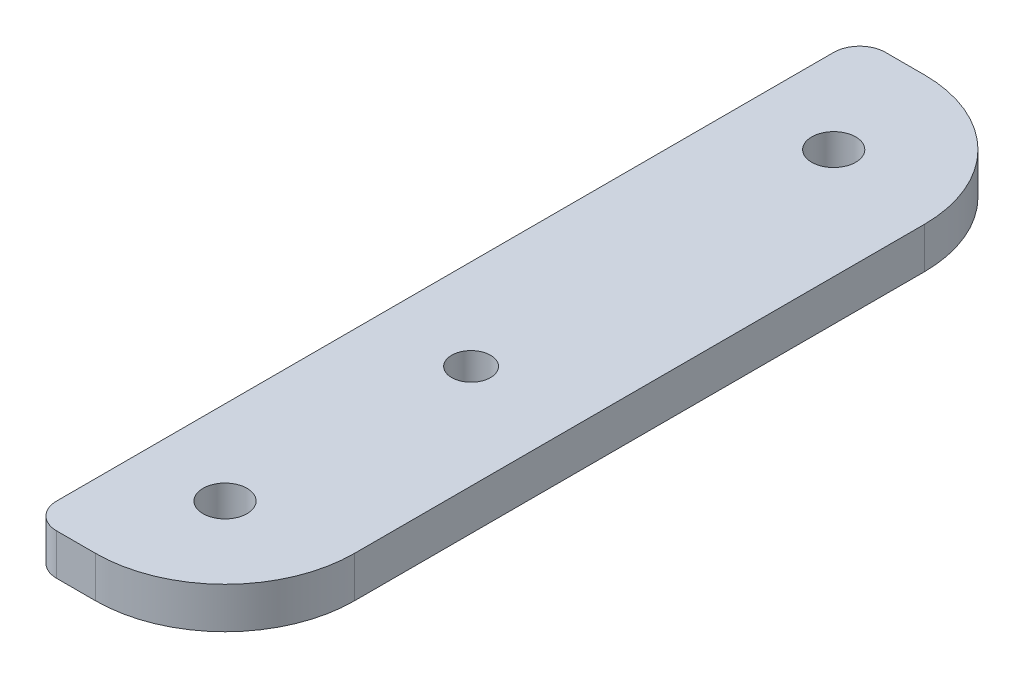
from build123d import *

# Parameters (mm, degrees)
BOSS_EXTRUDE2_DEPTH = 3.175
SKETCH3_R           = 1.7
CUT_EXTRUDE2_DEPTH  = 3.175
SKETCH4_R           = 1.5
CUT_EXTRUDE3_DEPTH  = 3.175
SKETCH5_W           = 61.765088801
SKETCH5_H           = 64
CUT_EXTRUDE4_DEPTH  = 3.175
FILLET1_R           = 2


with BuildPart() as part:
    # Sketch1 → Boss-Extrude2 (new body)
    with BuildSketch(Plane(origin=(0, 0, 0), x_dir=(1, 0, 0), z_dir=(0, 1, 0))):
        with BuildLine():
            Line((-22, 32), (22, 32))
            ThreePointArc((22, 32), (29.071067812, 29.071067812), (32, 22))
            Line((32, 22), (32, -22))
            ThreePointArc((32, -22), (29.071067812, -29.071067812), (22, -32))
            Line((22, -32), (-22, -32))
            ThreePointArc((-22, -32), (-29.071067812, -29.071067812), (-32, -22))
            Line((-32, -22), (-32, 22))
            ThreePointArc((-32, 22), (-29.071067812, 29.071067812), (-22, 32))
        make_face()
    extrude(amount=BOSS_EXTRUDE2_DEPTH)

    # Sketch3 → Cut-Extrude2 (cut)
    with BuildSketch(Plane(origin=(0, 3.175, 0), x_dir=(1, 0, 0), z_dir=(0, 1, 0))):
        with Locations((-23.5, 23.5)):
            Circle(SKETCH3_R)
        with Locations((23.5, 23.5)):
            Circle(SKETCH3_R)
        with Locations((23.5, -23.5)):
            Circle(SKETCH3_R)
        with Locations((-23.5, -23.5)):
            Circle(SKETCH3_R)
    extrude(amount=-CUT_EXTRUDE2_DEPTH, mode=Mode.SUBTRACT)

    # Sketch4 → Cut-Extrude3 (cut)
    with BuildSketch(Plane(origin=(0, 3.175, 0), x_dir=(1, 0, 0), z_dir=(0, 1, 0))):
        with Locations((24, -5)):
            Circle(SKETCH4_R)
        with Locations((-24, -5)):
            Circle(SKETCH4_R)
    extrude(amount=-CUT_EXTRUDE3_DEPTH, mode=Mode.SUBTRACT)

    # Sketch5 → Cut-Extrude4 (cut)
    with BuildSketch(Plane(origin=(0, 3.175, 0), x_dir=(1, 0, 0), z_dir=(0, 1, 0))):
        with Locations((-13.882544401, 0)):
            Rectangle(SKETCH5_W, SKETCH5_H)
    extrude(amount=-CUT_EXTRUDE4_DEPTH, mode=Mode.SUBTRACT)

    # Fillet1
    fillet1_edges = [part.edges().sort_by_distance(p)[0] for p in [
        (17, 1.5875, 32),
        (17, 1.5875, -32),
    ]]
    fillet(fillet1_edges, radius=FILLET1_R)


solid = part.part
